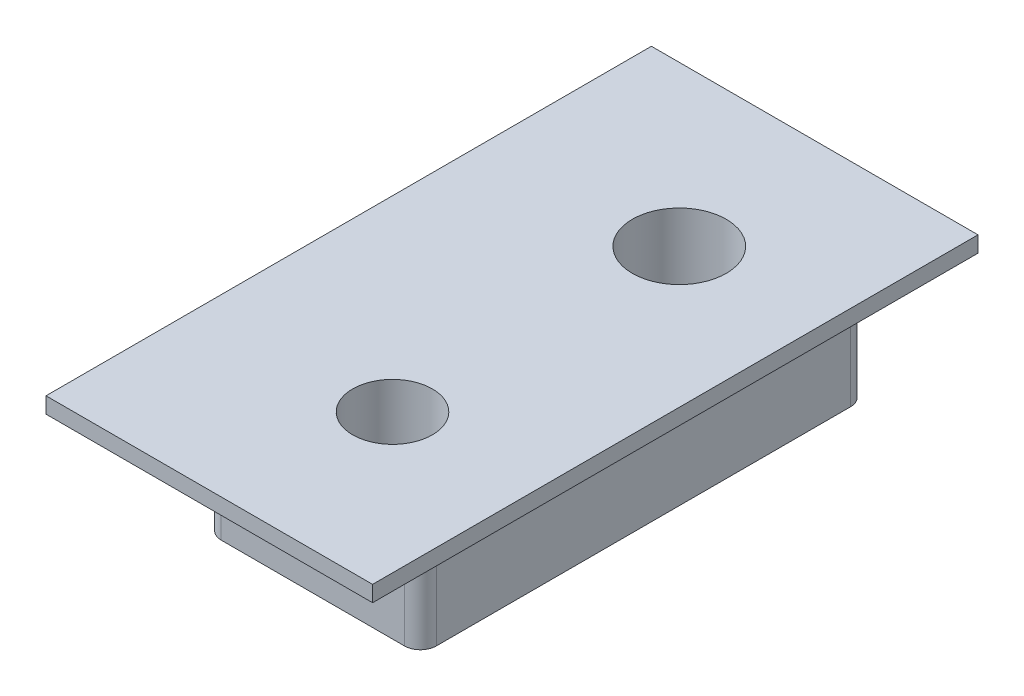
from build123d import *

# Parameters (mm, degrees)
SKETCH1_W             = 6.75
SKETCH1_H             = 3.175
EXTRUDE1_DEPTH        = 7
SKETCH6_W             = 11.75
SKETCH6_H             = 19
EXTRUDE2_DEPTH        = 0.5
F_4_CLEARANCE_HOLE1_D = 2.9464
SKETCH3_R             = 1.25
CUT_EXTRUDE1_DEPTH    = 4.675
FILLET1_R             = 0.5
SKETCH16_W            = 19
SKETCH16_H            = 0.5
CUT_EXTRUDE7_DEPTH    = 1.5


with BuildPart() as part:
    # Sketch1 → Extrude1 (new body, symmetric)
    with BuildSketch(Plane.XY):
        with Locations((0, 115.5875)):
            Rectangle(SKETCH1_W, SKETCH1_H)
    extrude(amount=EXTRUDE1_DEPTH, both=True)

    # Sketch6 → Extrude2 (add)
    with BuildSketch(Plane(origin=(0, 117.175, 0), x_dir=(1, 0, 0), z_dir=(0, 1, 0))):
        Rectangle(SKETCH6_W, SKETCH6_H)
    extrude(amount=EXTRUDE2_DEPTH)

    # 4 Clearance Hole1 (through all)
    with Locations(Plane(origin=(-0.355703292, 117.675, 3.885176073), x_dir=(-1, 0, 0), z_dir=(0, 1, 0))):
        with Locations((-0.355703292, -8.385176073)):
            Hole(F_4_CLEARANCE_HOLE1_D / 2)

    # Sketch3 → Cut-Extrude1 (cut, through all)
    with BuildSketch(Plane(origin=(0, 117.675, 0), x_dir=(1, 0, 0), z_dir=(0, 1, 0))):
        with Locations(Location((0, -4.5, 0), (0, 0, 270))):  # turned: the seam where the file's is
            Circle(SKETCH3_R)
    extrude(amount=-CUT_EXTRUDE1_DEPTH, mode=Mode.SUBTRACT)

    # Fillet1
    fillet1_edges = [part.edges().sort_by_distance(p)[0] for p in [
        (-3.375, 115.5875, 7),
        (-3.375, 115.5875, -7),
        (3.375, 115.5875, -7),
        (3.375, 115.5875, 7),
    ]]
    fillet(fillet1_edges, radius=FILLET1_R)

    # Sketch16 → Cut-Extrude7 (cut)
    with BuildSketch(Plane(origin=(5.875, 0, 0), x_dir=(0, 0, -1), z_dir=(1, 0, 0))):
        with Locations((0, 117.425)):
            Rectangle(SKETCH16_W, SKETCH16_H)
    extrude(amount=-CUT_EXTRUDE7_DEPTH, mode=Mode.SUBTRACT)


solid = part.part
